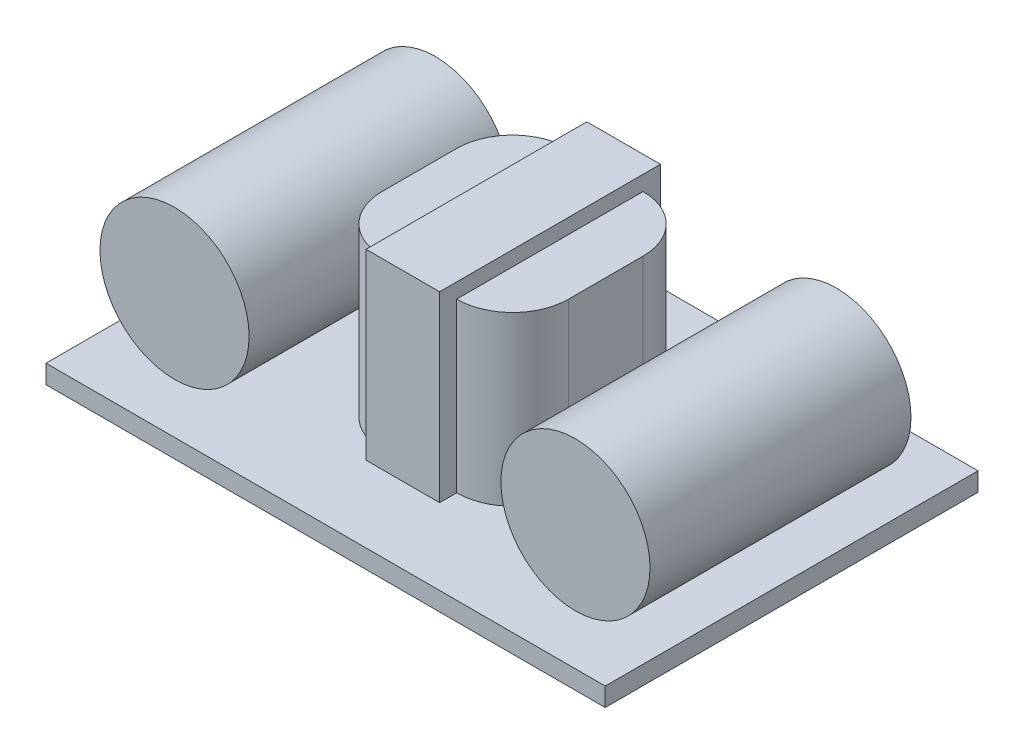
from build123d import *

# Parameters (mm, degrees)
SKETCH1_W             = 30
SKETCH1_H             = 20
BOSS_EXTRUDE1_DEPTH   = 1
SKETCH3_R             = 4
BOSS_EXTRUDE2_DEPTH   = 7
BOSS_EXTRUDE2_2_DEPTH = 7
SKETCH4_W             = 10
SKETCH4_H             = 10
BOSS_EXTRUDE3_DEPTH   = 10
FILLET1_R             = 3
SKETCH5_W             = 11.846582311
SKETCH5_H             = 9.799674645
BOSS_EXTRUDE4_DEPTH   = 3.946978


with BuildPart() as part:
    # Sketch1 → Boss-Extrude1 (new body)
    with BuildSketch(Plane(origin=(0, 0, 0), x_dir=(1, 0, 0), z_dir=(0, 1, 0))):
        with Locations((1.907090465, 0.427872861)):
            Rectangle(SKETCH1_W, SKETCH1_H)
    extrude(amount=BOSS_EXTRUDE1_DEPTH)

    # Sketch4 → Boss-Extrude3 (add)
    with BuildSketch(Plane(origin=(0, 0, 0), x_dir=(1, 0, 0), z_dir=(0, 1, 0))):
        with Locations((1.946977958, 0.418889495)):
            Rectangle(SKETCH4_W, SKETCH4_H)
    extrude(amount=BOSS_EXTRUDE3_DEPTH)

    # Fillet1
    fillet1_edges = [part.edges().sort_by_distance(p)[0] for p in [
        (-3.053022042, 5.5, -5.418889495),
        (-3.053022042, 5.5, 4.581110505),
        (6.946977958, 5.5, 4.581110505),
        (6.946977958, 5.5, -5.418889495),
    ]]
    fillet(fillet1_edges, radius=FILLET1_R)

    # Sketch5 → Boss-Extrude4 (add)
    with BuildSketch(Plane(origin=(0, 0, 0), x_dir=(0, 0, -1), z_dir=(1, 0, 0))):
        with Locations((0.42787286, 5.899837323)):
            Rectangle(SKETCH5_W, SKETCH5_H)
    extrude(amount=BOSS_EXTRUDE4_DEPTH)


with BuildPart() as body_2:
    # Sketch3 → Boss-Extrude2 (new body, symmetric)
    with BuildSketch(Plane.XY):
        with Locations((-8.77028568, 5.120167101)):
            Circle(SKETCH3_R)
    extrude(amount=BOSS_EXTRUDE2_DEPTH, both=True)


with BuildPart() as body_3:
    # Sketch3 → Boss-Extrude2 2 (new body, symmetric)
    with BuildSketch(Plane.XY):
        with Locations((12.738987248, 5.120167101)):
            Circle(SKETCH3_R)
    extrude(amount=BOSS_EXTRUDE2_2_DEPTH, both=True)


solid = Compound([part.part, body_2.part, body_3.part])
